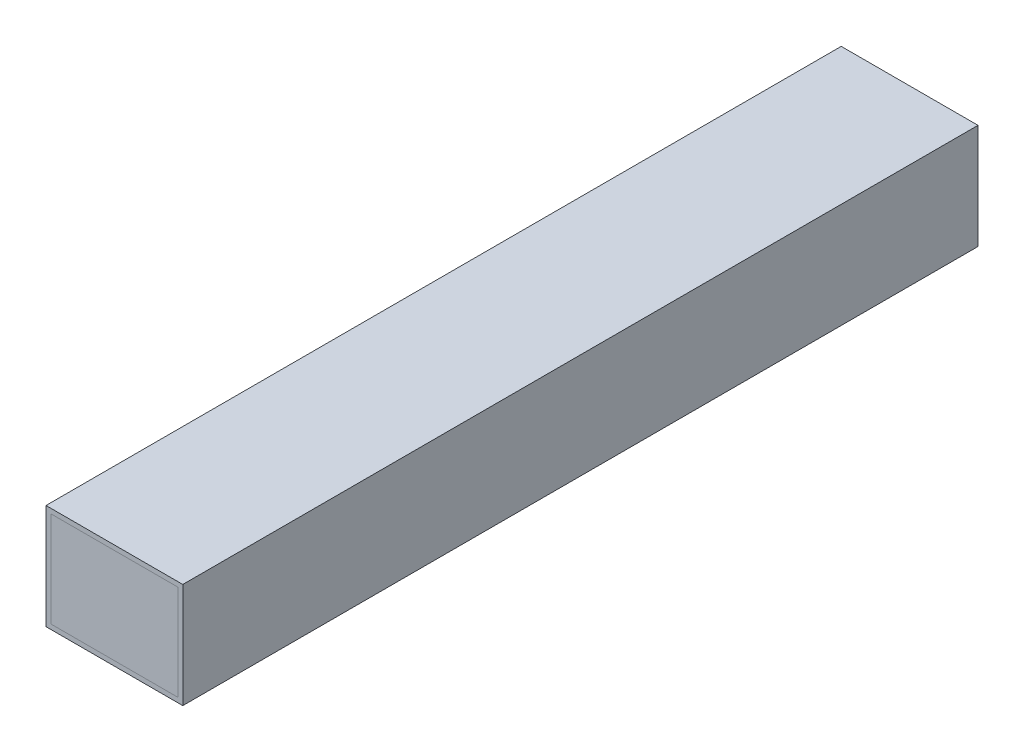
from build123d import *

# Parameters (mm, degrees)
SKETCH1_W             = 43
SKETCH1_H             = 33
SKETCH1_W_2           = 40
SKETCH1_H_2           = 30
EXTRUDE_THIN1_DEPTH   = 125
SKETCH2_W             = 30
SKETCH2_H             = 1
BOSS_EXTRUDE1_DEPTH   = 20
BOSS_EXTRUDE1_2_DEPTH = 20
BOSS_EXTRUDE1_3_DEPTH = 20
SKETCH6_W             = 39.996661802
SKETCH6_H             = 31.000580386
BOSS_EXTRUDE2_DEPTH   = 125


with BuildPart() as part:
    # Sketch1 → Extrude-Thin1 (new body, symmetric)
    with BuildSketch(Plane.XY):
        Rectangle(SKETCH1_W, SKETCH1_H)
        Rectangle(SKETCH1_W_2, SKETCH1_H_2, mode=Mode.SUBTRACT)
    extrude(amount=EXTRUDE_THIN1_DEPTH, both=True)


with BuildPart() as body_2:
    # Sketch2 → Boss-Extrude1 (new body, symmetric)
    with BuildSketch(Plane(origin=(0, 0, 0), x_dir=(0, 0, -1), z_dir=(1, 0, 0))):
        with Locations((0, -15.5)):
            Rectangle(SKETCH2_W, SKETCH2_H)
    extrude(amount=BOSS_EXTRUDE1_DEPTH, both=True)


with BuildPart() as body_3:
    # Sketch2 → Boss-Extrude1 2 (new body, symmetric)
    with BuildSketch(Plane(origin=(0, 0, 0), x_dir=(0, 0, -1), z_dir=(1, 0, 0))):
        with Locations((-40, -15.5)):
            Rectangle(SKETCH2_W, SKETCH2_H)
    extrude(amount=BOSS_EXTRUDE1_2_DEPTH, both=True)


with BuildPart() as body_4:
    # Sketch2 → Boss-Extrude1 3 (new body, symmetric)
    with BuildSketch(Plane(origin=(0, 0, 0), x_dir=(0, 0, -1), z_dir=(1, 0, 0))):
        with Locations((40, -15.5)):
            Rectangle(SKETCH2_W, SKETCH2_H)
    extrude(amount=BOSS_EXTRUDE1_3_DEPTH, both=True)


with BuildPart() as body_5:
    # Sketch3 → Revolve1 (revolve)
    with BuildSketch(Plane(origin=(0, 0, 0), x_dir=(1, 0, 0), z_dir=(0, 1, 0))):
        with BuildLine():
            Line((-7.65326093, 40.723479344), (7.65326093, 40.723479344))
            ThreePointArc((7.65326093, 40.723479344), (0, 48.376740274), (-7.65326093, 40.723479344))
        make_face()
    revolve(axis=Axis((-7.65326093, 0, -40.723479344), (1, 0, 0)))

    # Sketch5 → Revolve2 (revolve)
    with BuildSketch(Plane(origin=(0, 0, 0), x_dir=(1, 0, 0), z_dir=(0, 1, 0))):
        with BuildLine():
            Line((0, -100), (-2.640084996, -90.050652638))
            Line((-2.640084996, -90.050652638), (-0.35, -90.050652638))
            ThreePointArc((-0.35, -90.050652638), (-0.314644661, -90.036007977), (-0.3, -90.000652638))
            Line((-0.3, -90.000652638), (-0.3, 100))
            Line((-0.3, 100), (0, 100))
            Line((0, 100), (0, -100))
        make_face()
    revolve(axis=Axis((0, 0, 100), (0, 0, -1)))


with BuildPart() as body_6:
    # Sketch6 → Boss-Extrude2 (new body, symmetric)
    with BuildSketch(Plane.XY):
        with Locations((-0.001669099, -0.500290193)):
            Rectangle(SKETCH6_W, SKETCH6_H)
    extrude(amount=BOSS_EXTRUDE2_DEPTH, both=True)


solid = Compound([part.part, body_2.part, body_3.part, body_4.part, body_5.part, body_6.part])
